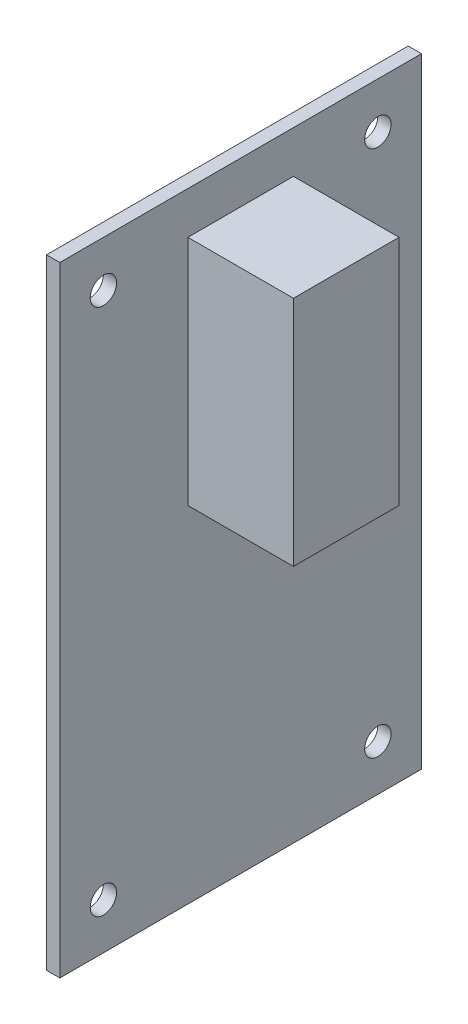
from build123d import *

# Parameters (mm, degrees)
SKETCH1_W          = 43.5102
SKETCH1_H          = 74.549
EXTRUDE1_DEPTH     = 1.6002
SKETCH2_R          = 1.5875
CUT_EXTRUDE1_DEPTH = 2.6002
SKETCH3_W          = 12.7
SKETCH3_H          = 27.94
EXTRUDE2_DEPTH     = 12.7


with BuildPart() as part:
    # Sketch1 → Extrude1 (new body)
    with BuildSketch(Plane(origin=(0, 0, 0), x_dir=(0, 0, -1), z_dir=(1, 0, 0))):
        with Locations((21.7551, 37.2745)):
            Rectangle(SKETCH1_W, SKETCH1_H)
    extrude(amount=EXTRUDE1_DEPTH)

    # Sketch2 → Cut-Extrude1 (cut, through all)
    with BuildSketch(Plane(origin=(1.6002, 0, 0), x_dir=(0, 0, -1), z_dir=(1, 0, 0))):
        with Locations((5.2451, 69.0245)):
            Circle(SKETCH2_R)
        with Locations((38.2651, 69.0245)):
            Circle(SKETCH2_R)
        with Locations((38.2651, 5.5245)):
            Circle(SKETCH2_R)
        with Locations((5.2451, 5.5245)):
            Circle(SKETCH2_R)
    extrude(amount=-CUT_EXTRUDE1_DEPTH, mode=Mode.SUBTRACT)

    # Sketch3 → Extrude2 (add)
    with BuildSketch(Plane(origin=(1.6002, 0, 0), x_dir=(0, 0, -1), z_dir=(1, 0, 0))):
        with Locations((21.7551, 55.499)):
            Rectangle(SKETCH3_W, SKETCH3_H)
    extrude(amount=EXTRUDE2_DEPTH)


solid = part.part
